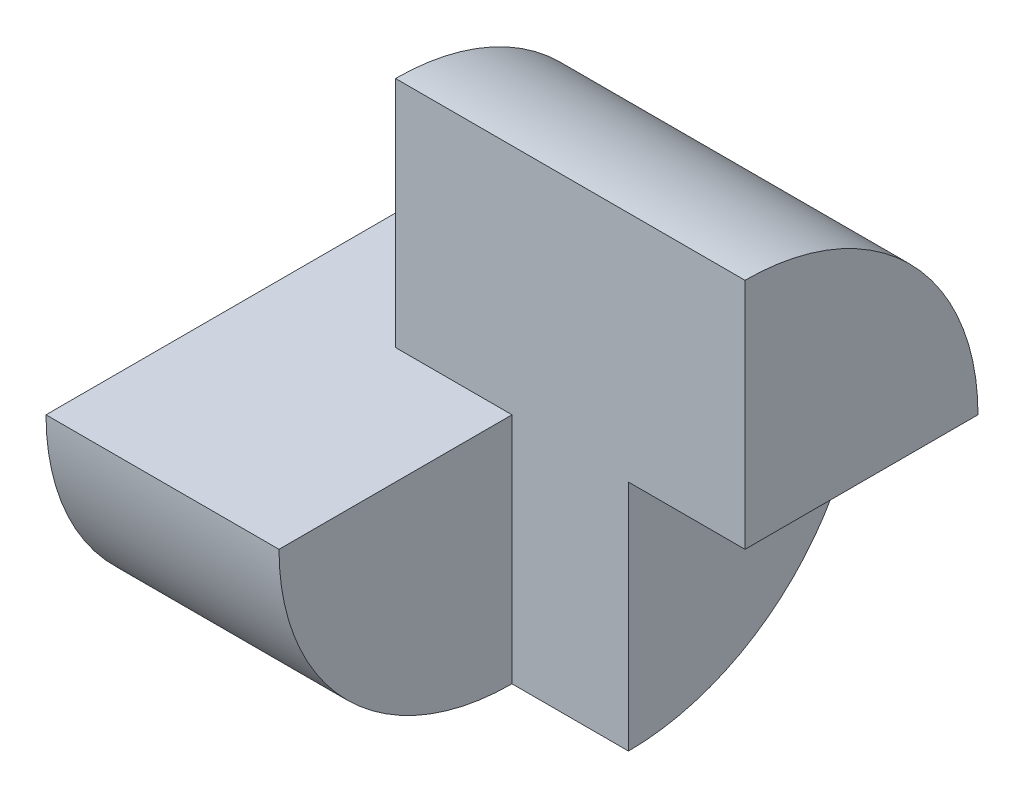
from build123d import *

# Parameters (mm, degrees)
SKETCH1_W           = 40
SKETCH1_H           = 40
BOSS_EXTRUDE1_DEPTH = 40
SKETCH2_W           = 10
SKETCH2_H           = 20
CUT_EXTRUDE1_DEPTH  = 40
SKETCH3_W           = 20
SKETCH3_H           = 20
CUT_EXTRUDE2_DEPTH  = 40
CUT_EXTRUDE3_DEPTH  = 40
SKETCH5_W           = 20
SKETCH5_H           = 20
CUT_EXTRUDE4_DEPTH  = 10
CUT_EXTRUDE6_DEPTH  = 43


with BuildPart() as part:
    # Sketch1 → Boss-Extrude1 (new body)
    with BuildSketch(Plane.XY):
        with Locations((20, 20)):
            Rectangle(SKETCH1_W, SKETCH1_H)
    extrude(amount=BOSS_EXTRUDE1_DEPTH)

    # Sketch2 → Cut-Extrude1 (cut)
    with BuildSketch(Plane.XY.offset(40)):
        with Locations((5, 30)):
            Rectangle(SKETCH2_W, SKETCH2_H)
        with Locations((35, 10)):
            Rectangle(SKETCH2_W, SKETCH2_H)
    extrude(amount=-CUT_EXTRUDE1_DEPTH, mode=Mode.SUBTRACT)

    # Sketch3 → Cut-Extrude2 (cut)
    with BuildSketch(Plane.ZY.offset(-10)):
        with Locations((30, 30)):
            Rectangle(SKETCH3_W, SKETCH3_H)
    extrude(amount=-CUT_EXTRUDE2_DEPTH, mode=Mode.SUBTRACT)

    # Sketch4 → Cut-Extrude3 (cut)
    with BuildSketch(Plane.ZY.offset(-10)):
        with BuildLine():
            Line((20, 40), (0, 40))
            Line((0, 40), (0, 20))
            ThreePointArc((0, 20), (5.857864376, 34.142135624), (20, 40))
        make_face()
    extrude(amount=-CUT_EXTRUDE3_DEPTH, mode=Mode.SUBTRACT)

    # Sketch5 → Cut-Extrude4 (cut)
    with BuildSketch(Plane(origin=(30, 0, 0), x_dir=(0, 0, -1), z_dir=(1, 0, 0))):
        with Locations((-30, 10)):
            Rectangle(SKETCH5_W, SKETCH5_H)
    extrude(amount=-CUT_EXTRUDE4_DEPTH, mode=Mode.SUBTRACT)

    # Sketch6 → Cut-Extrude6 (cut)
    with BuildSketch(Plane.ZY):
        with BuildLine():
            ThreePointArc((20, 0), (5.857864376, 5.857864376), (0, 20))
            Line((0, 20), (0, 0))
            Line((0, 0), (20, 0))
        make_face()
        with BuildLine():
            ThreePointArc((40, 20), (34.142135624, 5.857864376), (20, 0))
            Line((20, 0), (40, 0))
            Line((40, 0), (40, 20))
        make_face()
    extrude(amount=-CUT_EXTRUDE6_DEPTH, mode=Mode.SUBTRACT)


solid = part.part
